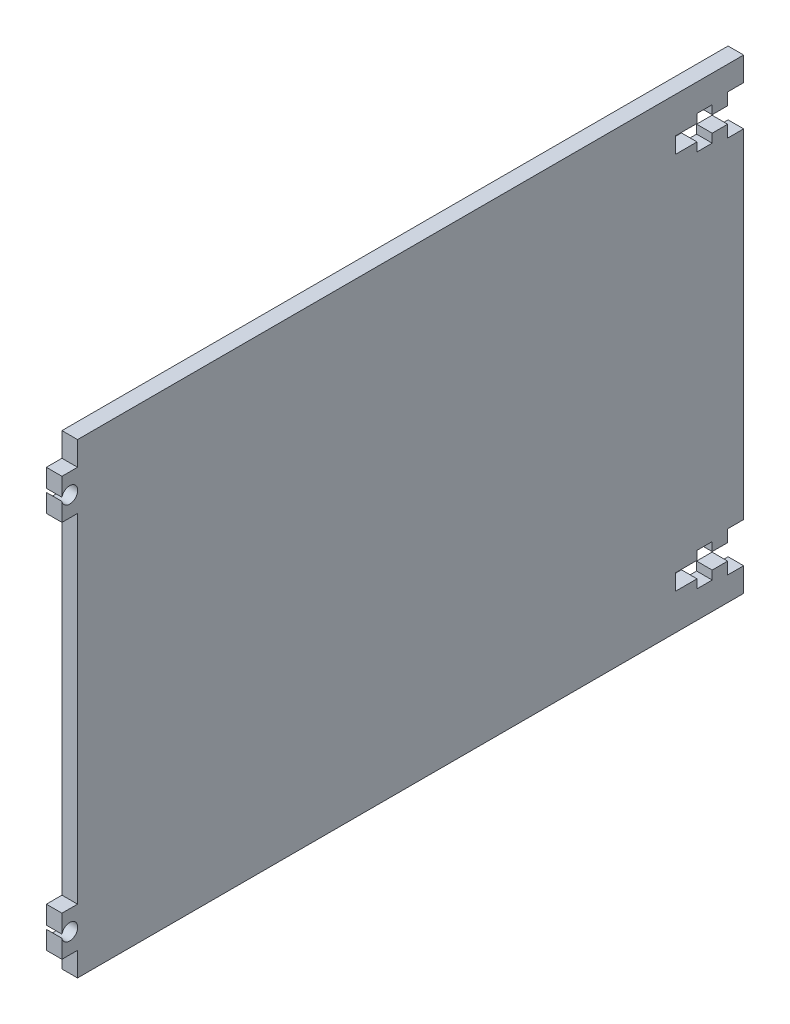
from build123d import *

# Parameters (mm, degrees)
BOSS_EXTRUDE1_DEPTH = 2.9718


with BuildPart() as part:
    # Sketch2 → Boss-Extrude1 (new body)
    with BuildSketch(Plane(origin=(0, 0, 0), x_dir=(0, 0, -1), z_dir=(1, 0, 0))):
        with BuildLine():
            Line((-73.009928621, 43.676956522), (53.990071379, 43.676956522))
            Line((53.990071379, 43.676956522), (53.990071379, 39.104956522))
            Line((53.990071379, 39.104956522), (50.942071379, 39.104956522))
            Line((50.942071379, 39.104956522), (50.942071379, 36.818956522))
            Line((50.942071379, 36.818956522), (47.989076338, 36.818956522))
            Line((47.989076338, 36.818956522), (47.989076338, 38.469956522))
            Line((47.989076338, 38.469956522), (45.100071379, 38.469956522))
            Line((45.100071379, 38.469956522), (45.100071379, 36.818956522))
            Line((45.100071379, 36.818956522), (41.036071379, 36.818956522))
            Line((41.036071379, 36.818956522), (41.036071379, 33.770956522))
            Line((41.036071379, 33.770956522), (45.100071379, 33.770956522))
            Line((45.100071379, 33.770956522), (45.100071379, 32.119956522))
            Line((45.100071379, 32.119956522), (47.989076338, 32.119956522))
            Line((47.989076338, 32.119956522), (47.989076338, 33.770956522))
            Line((47.989076338, 33.770956522), (50.942071379, 33.770956522))
            Line((50.942071379, 33.770956522), (50.942071379, 31.484956522))
            Line((50.942071379, 31.484956522), (53.990071379, 31.484956522))
            Line((53.990071379, 31.484956522), (53.990071379, -33.031043478))
            Line((53.990071379, -33.031043478), (50.942071379, -33.031043478))
            Line((50.942071379, -33.031043478), (50.942071379, -35.317043478))
            Line((50.942071379, -35.317043478), (47.989076338, -35.317043478))
            Line((47.989076338, -35.317043478), (47.989076338, -33.666043478))
            Line((47.989076338, -33.666043478), (45.100071379, -33.666043478))
            Line((45.100071379, -33.666043478), (45.100071379, -35.317043478))
            Line((45.100071379, -35.317043478), (41.036071379, -35.317043478))
            Line((41.036071379, -35.317043478), (41.036071379, -38.365043478))
            Line((41.036071379, -38.365043478), (45.100071379, -38.365043478))
            Line((45.100071379, -38.365043478), (45.100071379, -40.016043478))
            Line((45.100071379, -40.016043478), (47.989076338, -40.016043478))
            Line((47.989076338, -40.016043478), (47.989076338, -38.365043478))
            Line((47.989076338, -38.365043478), (50.942071379, -38.365043478))
            Line((50.942071379, -38.365043478), (50.942071379, -40.651043478))
            Line((50.942071379, -40.651043478), (53.990071379, -40.651043478))
            Line((53.990071379, -40.651043478), (53.990071379, -45.223043478))
            Line((53.990071379, -45.223043478), (-73.009928621, -45.223043478))
            Line((-73.009928621, -45.223043478), (-73.009928621, -40.651043478))
            Line((-73.009928621, -40.651043478), (-75.981728621, -40.651043478))
            Line((-75.981728621, -40.651043478), (-75.981728621, -37.179683686))
            ThreePointArc((-75.981728621, -37.179683686), (-72.971828621, -36.841043478), (-75.981728621, -36.502403271))
            Line((-75.981728621, -36.502403271), (-75.981728621, -33.031043478))
            Line((-75.981728621, -33.031043478), (-73.009928621, -33.031043478))
            Line((-73.009928621, -33.031043478), (-73.009928621, 31.484956522))
            Line((-73.009928621, 31.484956522), (-75.981728621, 31.484956522))
            Line((-75.981728621, 31.484956522), (-75.981728621, 34.956316314))
            ThreePointArc((-75.981728621, 34.956316314), (-72.971828621, 35.294956522), (-75.981728621, 35.633596729))
            Line((-75.981728621, 35.633596729), (-75.981728621, 39.104956522))
            Line((-75.981728621, 39.104956522), (-73.009928621, 39.104956522))
            Line((-73.009928621, 39.104956522), (-73.009928621, 43.676956522))
        make_face()
    extrude(amount=BOSS_EXTRUDE1_DEPTH)


solid = part.part
